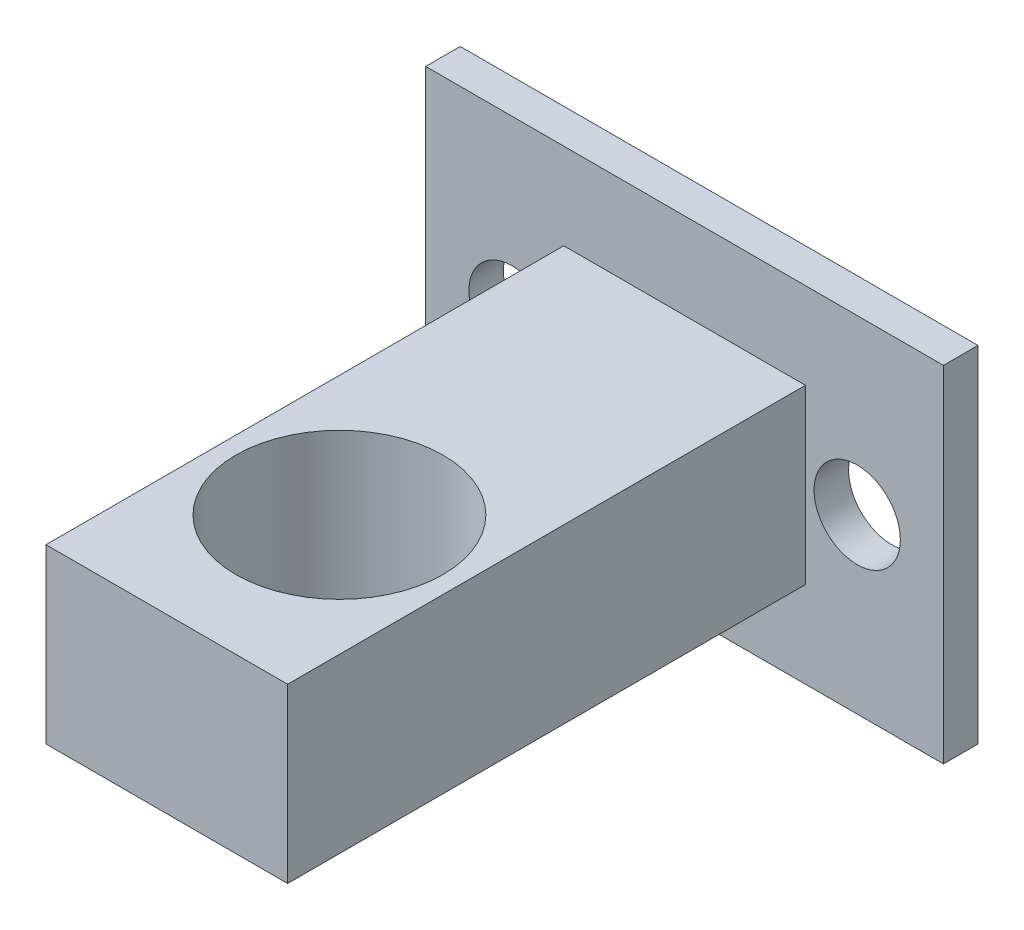
from build123d import *

# Parameters (mm, degrees)
SKETCH_1_R          = 2.5
EXTRUDE_1_DEPTH     = 2
EXTRUDE_2_DEPTH     = 30
SKETCH_4_R          = 6
CUT_EXTRUDE_1_DEPTH = 15


with BuildPart() as part:
    # 草图1 → 凸台-拉伸1 (new body)
    with BuildSketch(Plane.XY):
        Polygon((-30.821938658, 18.493163195), (-0.821938658, 18.493163195), (-0.821938658, 8.493163195), (-0.821938658, -1.506836805), (-30.821938658, -1.506836805), align=None)
        with Locations((-25.821938658, 8.493163195)):
            Circle(SKETCH_1_R, mode=Mode.SUBTRACT)
        with Locations((-5.821938658, 8.493163195)):
            Circle(SKETCH_1_R, mode=Mode.SUBTRACT)
    extrude(amount=EXTRUDE_1_DEPTH)

    # 草图2 → 凸台-拉伸2 (add)
    with BuildSketch(Plane.XY.offset(2)):
        Polygon((-22.821938658, 3.493163195), (-8.821938658, 3.493163195), (-8.821938658, 13.493163195), (-15.821938658, 13.493163195), (-22.821938658, 13.493163195), align=None)
    extrude(amount=EXTRUDE_2_DEPTH)

    # 草图4 → 切除-拉伸1 (cut)
    with BuildSketch(Plane.XZ.offset(-3.493163195)):
        with Locations((-15.821938658, 22)):
            Circle(SKETCH_4_R)
    extrude(amount=-CUT_EXTRUDE_1_DEPTH, mode=Mode.SUBTRACT)


solid = part.part
